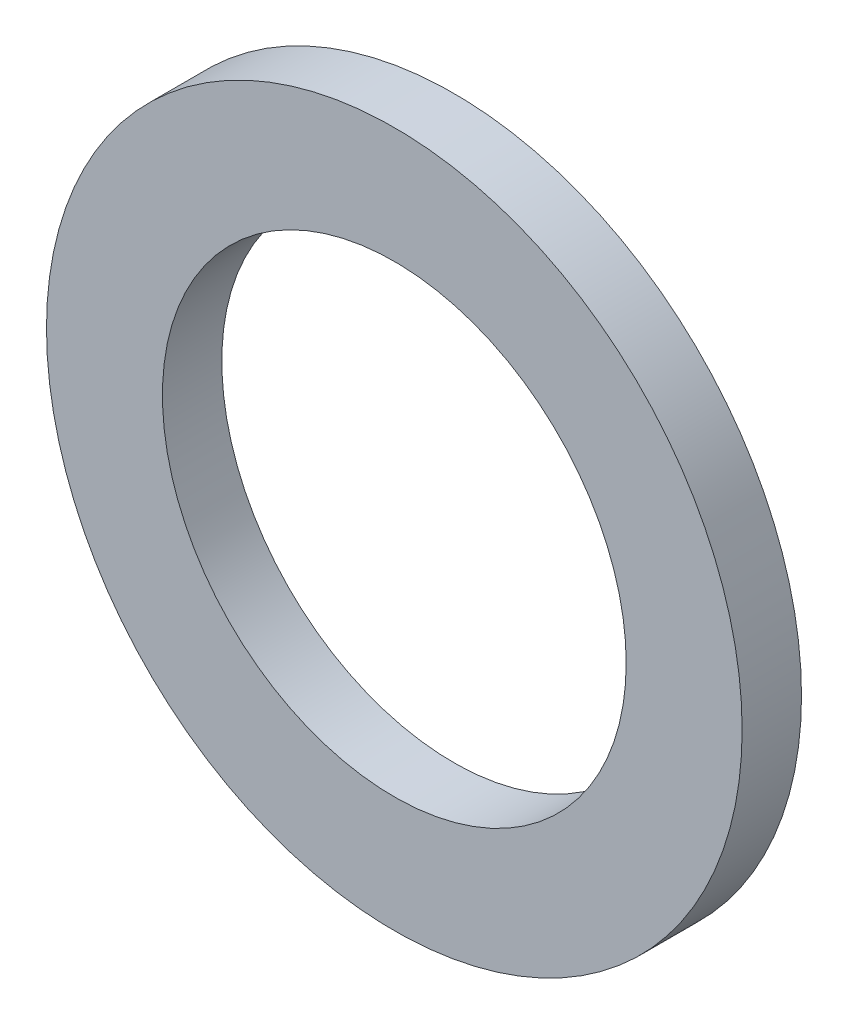
from build123d import *

# Parameters (mm, degrees)
SKETCH1_R           = 4.7625
SKETCH1_R_2         = 3.175
BOSS_EXTRUDE1_DEPTH = 0.8128


with BuildPart() as part:
    # Sketch1 → Boss-Extrude1 (new body)
    with BuildSketch(Plane.XY):
        Circle(SKETCH1_R)
        Circle(SKETCH1_R_2, mode=Mode.SUBTRACT)
    extrude(amount=BOSS_EXTRUDE1_DEPTH)


solid = part.part
